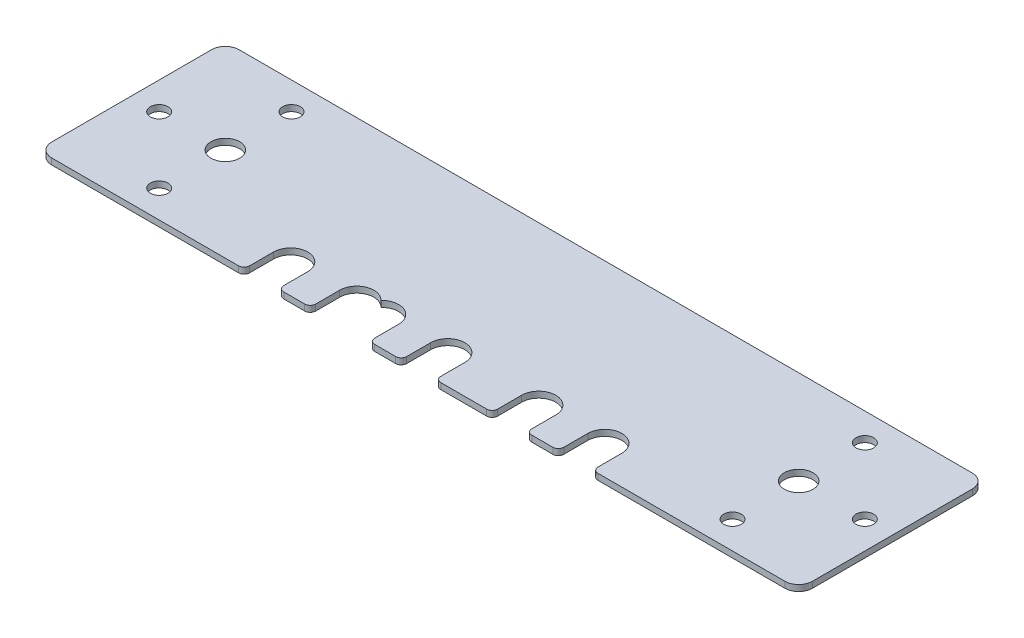
from build123d import *

# Parameters (mm, degrees)
BOSS_EXTRUDE1_DEPTH = 1.11
SKETCH3_R           = 2.6
SKETCH3_R_2         = 1.6
CUT_EXTRUDE5_DEPTH  = 12.11
SKETCH4_R           = 3.1
CUT_EXTRUDE6_DEPTH  = 2.11
SKETCH5_R           = 3.1
CUT_EXTRUDE7_DEPTH  = 2.11
SKETCH6_W           = 6.2
SKETCH6_H           = 6
SKETCH6_W_2         = 10.7
CUT_EXTRUDE8_DEPTH  = 2.11
FILLET1_R           = 1


with BuildPart() as part:
    # Sketch1 → Boss-Extrude1 (new body)
    with BuildSketch(Plane(origin=(0, 0, 0), x_dir=(1, 0, 0), z_dir=(0, 1, 0))):
        with BuildLine():
            Line((-66.5, -17), (66.5, -17))
            ThreePointArc((66.5, -17), (68.267766953, -16.267766953), (69, -14.5))
            Line((69, -14.5), (69, 14.5))
            ThreePointArc((69, 14.5), (68.267766953, 16.267766953), (66.5, 17))
            Line((66.5, 17), (-66.5, 17))
            ThreePointArc((-66.5, 17), (-68.267766953, 16.267766953), (-69, 14.5))
            Line((-69, 14.5), (-69, -14.5))
            ThreePointArc((-69, -14.5), (-68.267766953, -16.267766953), (-66.5, -17))
        make_face()
    extrude(amount=BOSS_EXTRUDE1_DEPTH)

    # Sketch3 → Cut-Extrude5 (cut, through all)
    with BuildSketch(Plane(origin=(0, -10, 0), x_dir=(1, 0, 0), z_dir=(0, 1, 0))):
        with Locations((-52, 0)):
            Circle(SKETCH3_R)
        with Locations((52, 0)):
            Circle(SKETCH3_R)
        with Locations((-52, 12)):
            Circle(SKETCH3_R_2)
        with Locations((-52, -12)):
            Circle(SKETCH3_R_2)
        with Locations((52, -12)):
            Circle(SKETCH3_R_2)
        with Locations((52, 12)):
            Circle(SKETCH3_R_2)
        with Locations((-64, 0)):
            Circle(SKETCH3_R_2)
        with Locations((64, 0)):
            Circle(SKETCH3_R_2)
    extrude(amount=CUT_EXTRUDE5_DEPTH, mode=Mode.SUBTRACT)

    # Sketch4 → Cut-Extrude6 (cut, through all)
    with BuildSketch(Plane.XZ):
        with Locations((0, 11.655)):
            Circle(SKETCH4_R)
        with Locations((-12, 11.655)):
            Circle(SKETCH4_R)
    extrude(amount=-CUT_EXTRUDE6_DEPTH, mode=Mode.SUBTRACT)

    # Sketch5 → Cut-Extrude7 (cut, through all)
    with BuildSketch(Plane.XZ):
        with Locations((-16.5, 11.655)):
            Circle(SKETCH5_R)
        with Locations((-28.5, 11.655)):
            Circle(SKETCH5_R)
        with Locations((28.5, 11.655)):
            Circle(SKETCH5_R)
        with Locations((16.5, 11.655)):
            Circle(SKETCH5_R)
    extrude(amount=-CUT_EXTRUDE7_DEPTH, mode=Mode.SUBTRACT)

    # Sketch6 → Cut-Extrude8 (cut, through all)
    with BuildSketch(Plane(origin=(0, 1.11, 0), x_dir=(1, 0, 0), z_dir=(0, 1, 0))):
        with Locations((-28.5, -14.655)):
            Rectangle(SKETCH6_W, SKETCH6_H)
        with Locations((-14.25, -14.655)):
            Rectangle(SKETCH6_W_2, SKETCH6_H)
        with Locations((0, -14.655)):
            Rectangle(SKETCH6_W, SKETCH6_H)
        with Locations((28.5, -14.655)):
            Rectangle(SKETCH6_W, SKETCH6_H)
        with Locations((16.5, -14.655)):
            Rectangle(SKETCH6_W, SKETCH6_H)
    extrude(amount=-CUT_EXTRUDE8_DEPTH, mode=Mode.SUBTRACT)

    # Fillet1
    fillet1_edges = [part.edges().sort_by_distance(p)[0] for p in [
        (-31.6, 0.555, 17),
        (-25.4, 0.555, 17),
        (-8.9, 0.555, 17),
        (-19.6, 0.555, 17),
        (-3.1, 0.555, 17),
        (3.1, 0.555, 17),
        (25.4, 0.555, 17),
        (31.6, 0.555, 17),
        (13.4, 0.555, 17),
        (19.6, 0.555, 17),
    ]]
    fillet(fillet1_edges, radius=FILLET1_R)


solid = part.part
